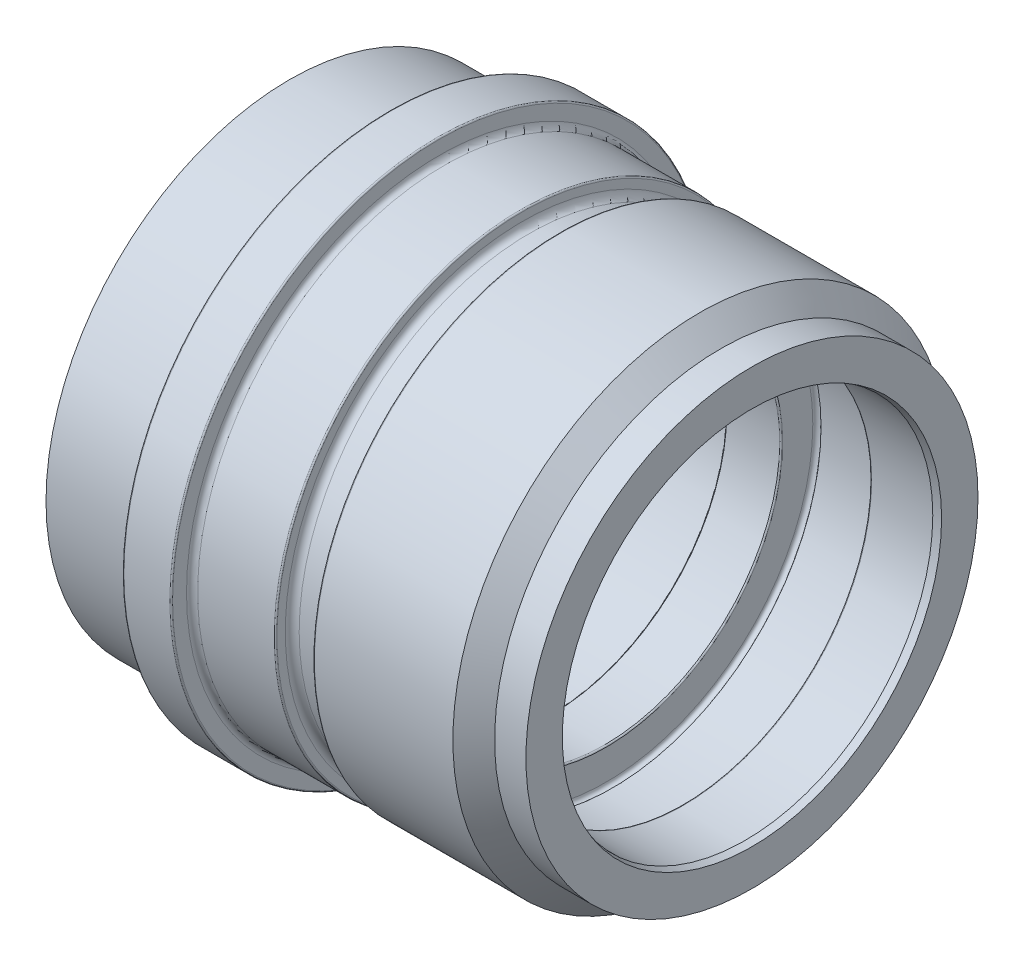
from build123d import *


with BuildPart() as part:
    # Sketch1 → Base-Revolve (revolve)
    with BuildSketch(Plane.XY):
        with BuildLine():
            Line((0, 36.3), (0, 38.3))
            ThreePointArc((0, 38.3), (-0.058578644, 38.441421356), (-0.2, 38.5))
            Line((-0.2, 38.5), (-6.8, 38.5))
            ThreePointArc((-6.8, 38.5), (-6.941421356, 38.441421356), (-7, 38.3))
            Line((-7, 38.3), (-7, 35.2))
            ThreePointArc((-7, 35.2), (-7.058578644, 35.058578644), (-7.2, 35))
            Line((-7.2, 35), (-21.5, 35))
            Line((-21.5, 35), (-21.5, 30.577350269))
            Line((-21.5, 30.577350269), (-20.5, 30))
            Line((-20.5, 30), (-14.8, 30))
            ThreePointArc((-14.8, 30), (-14.234314575, 29.765685425), (-14, 29.2))
            Line((-14, 29.2), (-14, 25.5))
            Line((-14, 25.5), (-9.2, 25.5))
            ThreePointArc((-9.2, 25.5), (-9.058578644, 25.558578644), (-9, 25.7))
            Line((-9, 25.7), (-9, 27.3))
            ThreePointArc((-9, 27.3), (-8.941421356, 27.441421356), (-8.8, 27.5))
            Line((-8.8, 27.5), (15.8, 27.5))
            ThreePointArc((15.8, 27.5), (15.941421356, 27.441421356), (16, 27.3))
            Line((16, 27.3), (16, 25.4))
            ThreePointArc((16, 25.4), (16.058578644, 25.258578644), (16.2, 25.2))
            Line((16.2, 25.2), (23.8, 25.2))
            ThreePointArc((23.8, 25.2), (23.941421356, 25.258578644), (24, 25.4))
            Line((24, 25.4), (24, 29.75))
            ThreePointArc((24, 29.75), (24.370590477, 30.232962913), (24.933012702, 30))
            Line((24.933012702, 30), (34.6, 30))
            ThreePointArc((34.6, 30), (34.882842712, 29.882842712), (35, 29.6))
            Line((35, 29.6), (35, 27.2))
            ThreePointArc((35, 27.2), (35.058578644, 27.058578644), (35.2, 27))
            Line((35.2, 27), (44, 27))
            Line((44, 27), (45, 27.267949192))
            Line((45, 27.267949192), (45, 32.5))
            Line((45, 32.5), (40.5, 32.5))
            Line((40.5, 32.5), (37.5, 35.5))
            Line((37.5, 35.5), (17.6, 35.5))
            ThreePointArc((17.6, 35.5), (17.458578644, 35.441421356), (17.4, 35.3))
            Line((17.4, 35.3), (17.4, 34.1))
            ThreePointArc((17.4, 34.1), (17.107106781, 33.392893219), (16.4, 33.1))
            Line((16.4, 33.1), (13, 33.1))
            ThreePointArc((13, 33.1), (12.292893219, 33.392893219), (12, 34.1))
            Line((12, 34.1), (12, 35.3))
            ThreePointArc((12, 35.3), (11.941421356, 35.441421356), (11.8, 35.5))
            Line((11.8, 35.5), (0.8, 35.5))
            ThreePointArc((0.8, 35.5), (0.234314575, 35.734314575), (0, 36.3))
        make_face()
    revolve(axis=Axis((0, 0, 0), (-1, 0, 0)))


solid = part.part
